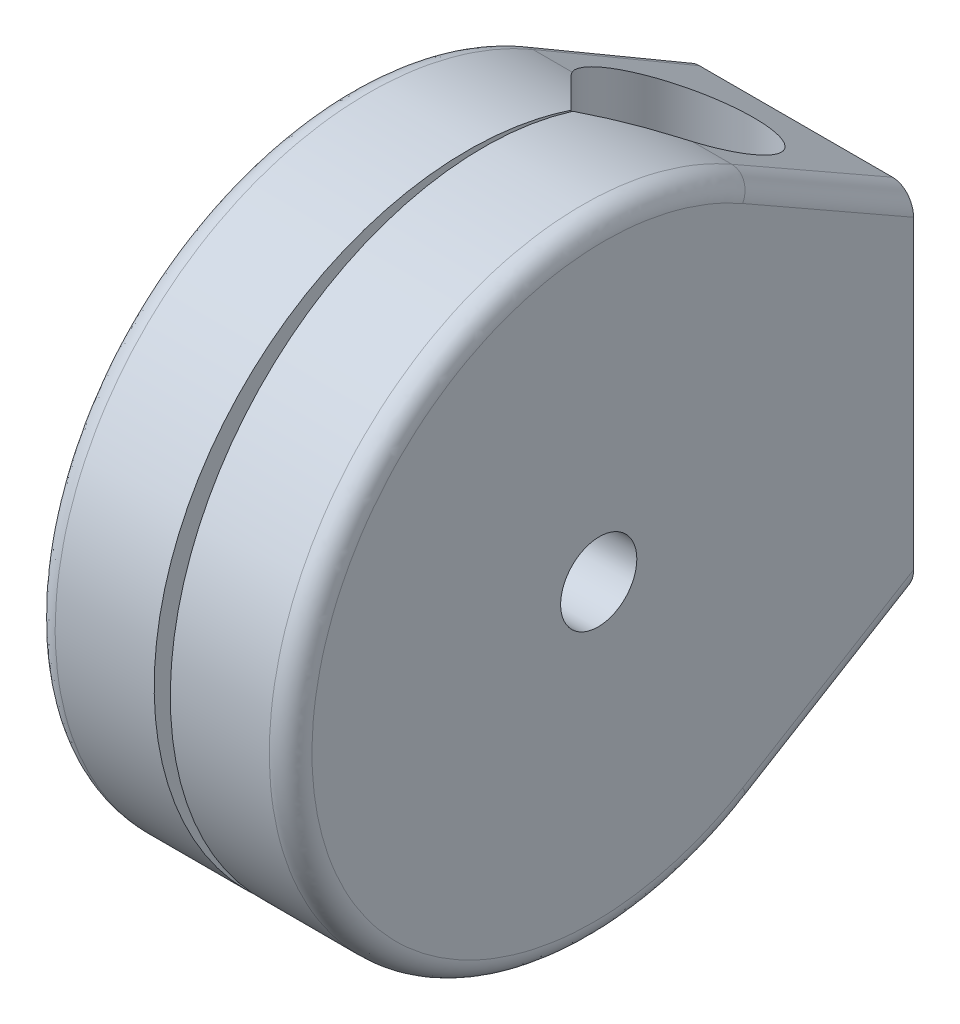
from build123d import *

# Parameters (mm, degrees)
BOSS_EXTRUDE1_DEPTH     = 16.668
CUT_EXTRUDE1_DEPTH      = 45.45
CUT_EXTRUDE1_DEPTH_BACK = 45.45
DRAFT1_ANGLE            = 1
CUT_EXTRUDE2_REACH      = 38.469
SKETCH3_R               = 5.5
CUT_EXTRUDE4_REACH      = 38.469
SKETCH5_R               = 5.5
FILLET1_R               = 3


with BuildPart() as part:
    # Sketch1 → Boss-Extrude1 (new body, symmetric)
    with BuildSketch(Plane(origin=(0, 0, 0), x_dir=(0, 0, -1), z_dir=(1, 0, 0))):
        with BuildLine():
            Line((22.225, 38.494829198), (45.45, 25.085869196))
            Line((45.45, 25.085869196), (45.45, -25.085869196))
            Line((45.45, -25.085869196), (22.225, -38.494829198))
            ThreePointArc((22.225, -38.494829198), (-44.45, 0), (22.225, 38.494829198))
        make_face()
    extrude(amount=BOSS_EXTRUDE1_DEPTH, both=True)

    # Sketch2 → Cut-Extrude1 (cut, two sides)
    with BuildSketch(Plane(origin=(0, 0, 0), x_dir=(1, 0, 0), z_dir=(0, 1, 0))) as cut_extrude1_sk:
        with BuildLine():
            Line((-7.588316422, 21.130183578), (-0.129046134, 13.670913289))
            Line((-0.129046134, 13.670913289), (-1.143550449, -44.45))
            Line((-1.143550449, -44.45), (1.143550449, -44.45))
            Line((1.143550449, -44.45), (0.129046134, 13.670913289))
            Line((0.129046134, 13.670913289), (7.588316422, 21.130183578))
            ThreePointArc((7.588316422, 21.130183578), (0, 39.45), (-7.588316422, 21.130183578))
        make_face()
    extrude(amount=CUT_EXTRUDE1_DEPTH, mode=Mode.SUBTRACT)
    extrude(cut_extrude1_sk.sketch, amount=-CUT_EXTRUDE1_DEPTH_BACK, mode=Mode.SUBTRACT)

    # Draft1
    draft1_faces = [part.faces().sort_by_distance(p)[0] for p in [
        (16.668, 0, -1.658648034),
        (-16.668, 0, -1.658648034),
    ]]
    draft(draft1_faces, Plane(origin=(16.668, 25.085869196, -45.45), x_dir=(-1, 0, 0), z_dir=(0, 0, -1)), DRAFT1_ANGLE)

    # Sketch3 → Cut-Extrude2 (cut, up to next)
    with BuildSketch(Plane(origin=(17.456014215, 0, -0.304695862), x_dir=(-0.017452406, 0, -0.999847695), z_dir=(0.999847695, 0, -0.017452406)), mode=Mode.PRIVATE) as cut_extrude2_sk1:
        with Locations((-0.304742275, 0)):
            Circle(SKETCH3_R)
    cut_extrude2_tool1 = extrude(cut_extrude2_sk1.sketch, amount=-CUT_EXTRUDE2_REACH, mode=Mode.PRIVATE) & part.part
    add(cut_extrude2_tool1.solids().sort_by_distance((17.461333, 0, 0))[0], mode=Mode.SUBTRACT)

    # Sketch5 → Cut-Extrude4 (cut, up to next)
    with BuildSketch(Plane(origin=(-17.456014215, 0, -0.304695862), x_dir=(-0.017452406, 0, 0.999847695), z_dir=(-0.999847695, 0, -0.017452406)), mode=Mode.PRIVATE) as cut_extrude4_sk1:
        with Locations((0.304742275, 0)):
            Circle(SKETCH5_R)
    cut_extrude4_tool1 = extrude(cut_extrude4_sk1.sketch, amount=-CUT_EXTRUDE4_REACH, mode=Mode.PRIVATE) & part.part
    add(cut_extrude4_tool1.solids().sort_by_distance((-17.461333, 0, 0))[0], mode=Mode.SUBTRACT)

    # Fillet1
    fillet1_edges = [part.edges().sort_by_distance(p)[0] for p in [
        (16.870696941, 31.790349197, -33.8375),
        (18.237210337, 0.000220739, 44.449999999),
        (-16.870696941, 31.790349197, -33.8375),
        (-16.870697084, -31.790353899, -33.837491856),
        (-18.237210337, 9.404e-06, 44.45),
        (16.870700278, -31.790459554, -33.837308856),
    ]]
    fillet(fillet1_edges, radius=FILLET1_R)


solid = part.part
